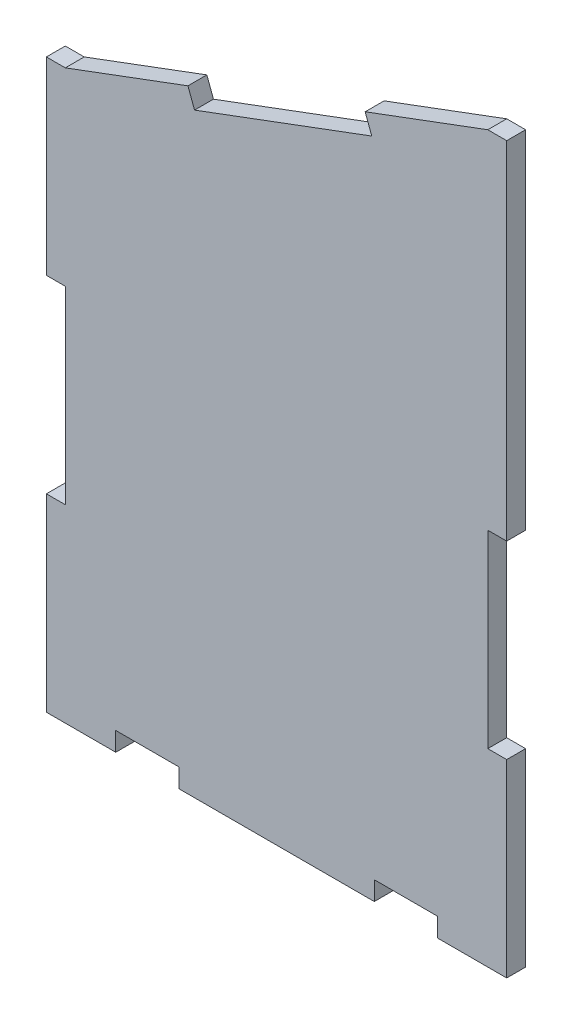
from build123d import *

# Parameters (mm, degrees)
BOSS_EXTRUDE1_DEPTH = 3


with BuildPart() as part:
    # Model → Boss-Extrude1 (new body)
    with BuildSketch(Plane.XY):
        Polygon((292.856281381, 249.969765788), (292.856281381, 194.969765788), (289.856281381, 194.969765788), (289.856281381, 164.969765788), (292.856281381, 164.969765788), (292.856281381, 134.969765788), (281.856281381, 134.969765788), (281.856281381, 137.969765788), (271.856281381, 137.969765788), (271.856281381, 134.969765788), (240.857809941, 134.969765788), (240.857809941, 137.969765788), (230.857809941, 137.969765788), (230.857809941, 134.969765788), (219.857809941, 134.969765788), (219.857809941, 164.969765788), (222.857809941, 164.969765788), (222.857809941, 194.969765788), (219.857809941, 194.969765788), (219.857809941, 224.969765788), (222.857809941, 224.969765788), (242.303545953, 232.225802976), (243.352338516, 229.415103035), (271.459337931, 239.903028658), (270.410545368, 242.7137286), (289.856281381, 249.969765788), align=None)
    extrude(amount=BOSS_EXTRUDE1_DEPTH)


solid = part.part
